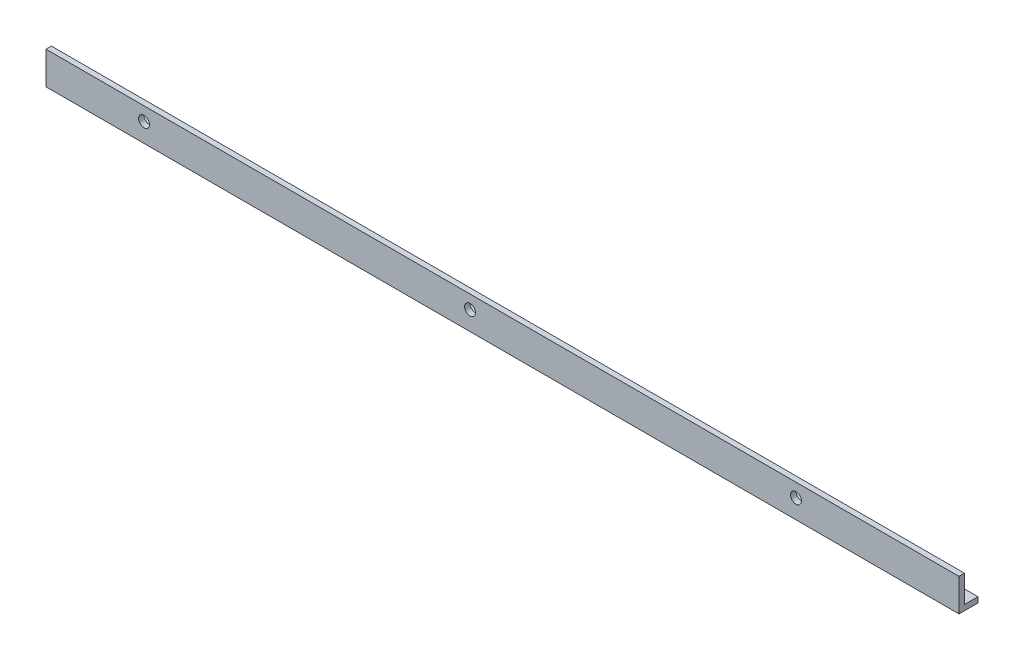
from build123d import *

# Parameters (mm, degrees)
SKETCH1_W           = 64.72
SKETCH1_H           = 10
BOSS_EXTRUDE1_DEPTH = 1
SKETCH2_W           = 64.72
SKETCH2_H           = 1
BOSS_EXTRUDE2_DEPTH = 5
BOSS_EXTRUDE3_DEPTH = 60
SKETCH4_W           = 1
SKETCH4_H           = 5
CUT_EXTRUDE1_DEPTH  = 125.72
SKETCH5_W           = 4.72
SKETCH5_H           = 6
CUT_EXTRUDE2_DEPTH  = 6
SKETCH6_W           = 120
SKETCH6_H           = 1
BOSS_EXTRUDE4_DEPTH = 1
SKETCH7_R           = 1
CUT_EXTRUDE3_DEPTH  = 7
SKETCH8_W           = 120
SKETCH8_H           = 2.5
CUT_EXTRUDE4_DEPTH  = 2
BOSS_EXTRUDE5_DEPTH = 48.05
SKETCH13_R          = 1
CUT_EXTRUDE5_DEPTH  = 2


with BuildPart() as part:
    # Sketch1 → Boss-Extrude1 (new body)
    with BuildSketch(Plane.XY):
        with Locations((17.76, 3.48)):
            Rectangle(SKETCH1_W, SKETCH1_H)
    extrude(amount=BOSS_EXTRUDE1_DEPTH)

    # Sketch2 → Boss-Extrude2 (add)
    with BuildSketch(Plane(origin=(0, 0, 0), x_dir=(-1, 0, 0), z_dir=(0, 0, -1))):
        with Locations((-17.76, -1.02)):
            Rectangle(SKETCH2_W, SKETCH2_H)
    extrude(amount=BOSS_EXTRUDE2_DEPTH)

    # Sketch3 → Boss-Extrude3 (add)
    with BuildSketch(Plane(origin=(50.12, 0, 0), x_dir=(0, 0, -1), z_dir=(1, 0, 0))):
        Polygon((-1, 8.48), (0, 8.48), (0, -0.52), (5, -0.52), (5, -1.52), (-1, -1.52), align=None)
    extrude(amount=BOSS_EXTRUDE3_DEPTH)

    # Sketch4 → Cut-Extrude1 (cut, through all)
    with BuildSketch(Plane(origin=(110.12, 0, 0), x_dir=(0, 0, -1), z_dir=(1, 0, 0))):
        with Locations((-0.5, 5.98)):
            Rectangle(SKETCH4_W, SKETCH4_H)
    extrude(amount=-CUT_EXTRUDE1_DEPTH, mode=Mode.SUBTRACT)

    # Sketch5 → Cut-Extrude2 (cut, through all)
    with BuildSketch(Plane(origin=(0, 3.48, 0), x_dir=(1, 0, 0), z_dir=(0, 1, 0))):
        with Locations((-12.24, 2)):
            Rectangle(SKETCH5_W, SKETCH5_H)
    extrude(amount=-CUT_EXTRUDE2_DEPTH, mode=Mode.SUBTRACT)

    # Sketch6 → Boss-Extrude4 (add)
    with BuildSketch(Plane(origin=(0, 3.48, 0), x_dir=(1, 0, 0), z_dir=(0, 1, 0))):
        with Locations((50.12, -0.5)):
            Rectangle(SKETCH6_W, SKETCH6_H)
    extrude(amount=BOSS_EXTRUDE4_DEPTH)

    # Sketch7 → Cut-Extrude3 (cut, through all)
    with BuildSketch(Plane.XY.offset(1)):
        with Locations((20.12, 1.98)):
            Circle(SKETCH7_R)
        with Locations((80.12, 1.98)):
            Circle(SKETCH7_R)
    extrude(amount=-CUT_EXTRUDE3_DEPTH, mode=Mode.SUBTRACT)

    # Sketch8 → Cut-Extrude4 (cut, through all)
    with BuildSketch(Plane(origin=(0, -0.52, 0), x_dir=(1, 0, 0), z_dir=(0, 1, 0))):
        with Locations((50.12, 3.75)):
            Rectangle(SKETCH8_W, SKETCH8_H)
    extrude(amount=-CUT_EXTRUDE4_DEPTH, mode=Mode.SUBTRACT)

    # Sketch11 → Boss-Extrude5 (add)
    with BuildSketch(Plane.ZY.offset(9.88)):
        Polygon((-2.5, -0.52), (-2.5, -1.52), (1, -1.52), (1, 4.48), (0, 4.48), (0, -0.52), align=None)
    extrude(amount=BOSS_EXTRUDE5_DEPTH)

    # Sketch13 → Cut-Extrude5 (cut, through all)
    with BuildSketch(Plane(origin=(0, 0, 0), x_dir=(-1, 0, 0), z_dir=(0, 0, -1))):
        with Locations((39.88, 1.98)):
            Circle(SKETCH13_R)
    extrude(amount=-CUT_EXTRUDE5_DEPTH, mode=Mode.SUBTRACT)


solid = part.part
